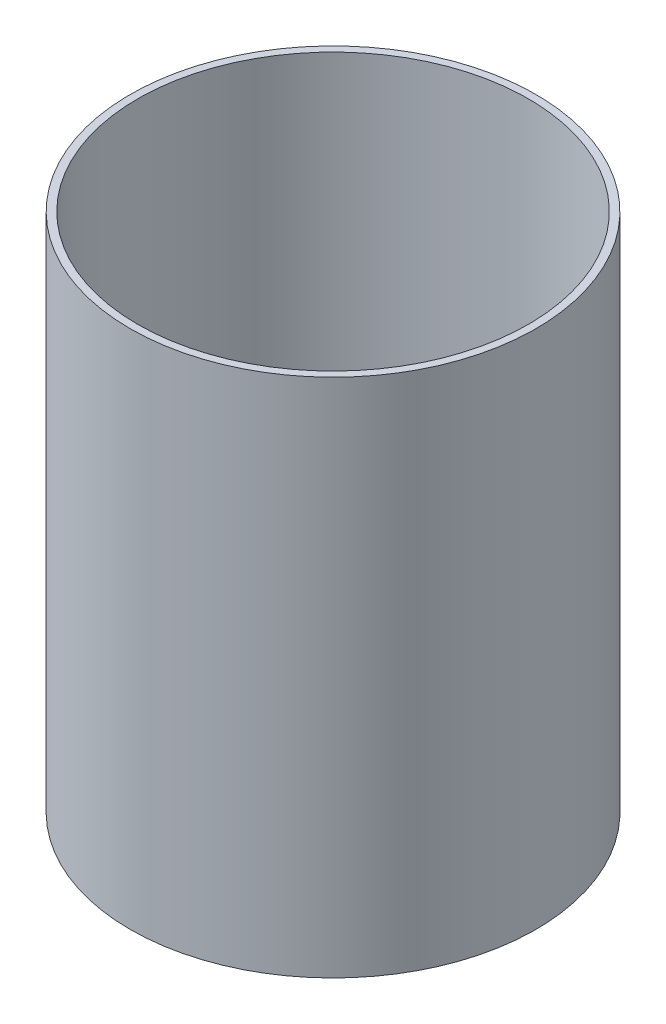
from build123d import *

# Parameters (mm, degrees)
SKETCH1_R           = 49.5173
SKETCH1_R_2         = 47.6885
BOSS_EXTRUDE1_DEPTH = 127


with BuildPart() as part:
    # Sketch1 → Boss-Extrude1 (new body)
    with BuildSketch(Plane(origin=(0, 0, 0), x_dir=(1, 0, 0), z_dir=(0, 1, 0))):
        Circle(SKETCH1_R)
        Circle(SKETCH1_R_2, mode=Mode.SUBTRACT)
    extrude(amount=BOSS_EXTRUDE1_DEPTH)


solid = part.part
